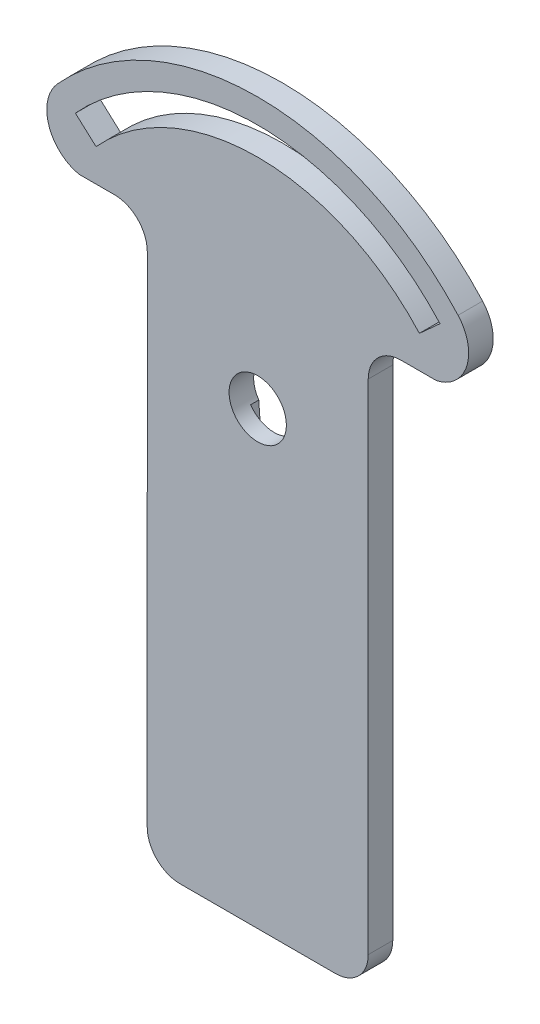
from build123d import *

# Parameters (mm, degrees)
CORTE_EXTERIOR_R        = 3.500002593
SALIENTE_EXTRUIR1_DEPTH = 3
CORTAR_EXTRUIR1_DEPTH   = 1
CORTAR_EXTRUIR2_DEPTH   = 0.1


with BuildPart() as part:
    # Corte exterior → Saliente-Extruir1 (new body)
    with BuildSketch(Plane.XY):
        with BuildLine():
            Line((47.504320945, 38.211786495), (51.847305041, 38.211786495))
            ThreePointArc((51.847305041, 38.211786495), (55.534254627, 41.572373104), (54.480090972, 46.448424641))
            ThreePointArc((54.480090972, 46.448424641), (30.004320476, 57.31391234), (5.528550918, 46.448424641))
            ThreePointArc((5.528550918, 46.448424641), (4.474387263, 41.572373104), (8.161336848, 38.211786495))
            Line((8.161336848, 38.211786495), (12.511035037, 38.211786495))
            ThreePointArc((12.511035037, 38.211786495), (15.339462162, 37.04021362), (16.511035037, 34.211786495))
            Line((16.511035037, 34.211786495), (16.504320945, -26.686088981))
            ThreePointArc((16.504320945, -26.686088981), (17.67589382, -29.514516106), (20.504320945, -30.686088981))
            Line((20.504320945, -30.686088981), (39.504320945, -30.686088981))
            ThreePointArc((39.504320945, -30.686088981), (42.33274807, -29.514516106), (43.504320945, -26.686088981))
            Line((43.504320945, -26.686088981), (43.504320945, 34.211786495))
            ThreePointArc((43.504320945, 34.211786495), (44.67589382, 37.04021362), (47.504320945, 38.211786495))
        make_face()
        with Locations((30.00431952, 24.313911283)):
            Circle(CORTE_EXTERIOR_R, mode=Mode.SUBTRACT)
        with BuildLine():
            ThreePointArc((52.277272453, 44.456319148), (30.004320476, 54.343913397), (7.731367869, 44.456320565))
            Line((7.731367869, 44.456320565), (10.253113799, 42.175794866))
            ThreePointArc((10.253113799, 42.175794866), (30.004320476, 50.943913397), (49.755526523, 42.175793449))
            Line((49.755526523, 42.175793449), (52.277272453, 44.456319148))
        make_face(mode=Mode.SUBTRACT)
    extrude(amount=SALIENTE_EXTRUIR1_DEPTH)

    # Grabado Superficie → Cortar-Extruir1 (cut)
    with BuildSketch(Plane.XY):
        with BuildLine():
            Line((32.873672963, 22.309708905), (31.999357171, 9.92309063))
            ThreePointArc((31.999357171, 9.92309063), (30.004320945, 8.063911283), (28.009284719, 9.92309063))
            Line((28.009284719, 9.92309063), (27.134968927, 22.309708905))
            ThreePointArc((27.134968927, 22.309708905), (30.004320945, 20.813910115), (32.873672963, 22.309708905))
        make_face()
    extrude(amount=CORTAR_EXTRUIR1_DEPTH, mode=Mode.SUBTRACT)

    # grabado linea medio → Cortar-Extruir2 (cut)
    with BuildSketch(Plane.XY):
        Polygon((43.479990352, -26.052604982), (35.339991301, -26.048672531), (35.337749708, -30.68867199), (32.817750002, -30.687454573), (32.819992183, -26.046238615), (16.48009071, -25.838344751), (16.491215962, -2.809563938), (32.831214056, -2.817457825), (32.833455649, 1.822541634), (35.353455355, 1.821324216), (35.351213761, -2.818675242), (39.411213288, -2.820636636), (39.407309823, -10.900635693), (43.487309347, -10.90260675), align=None)
    extrude(amount=CORTAR_EXTRUIR2_DEPTH, mode=Mode.SUBTRACT)


solid = part.part
